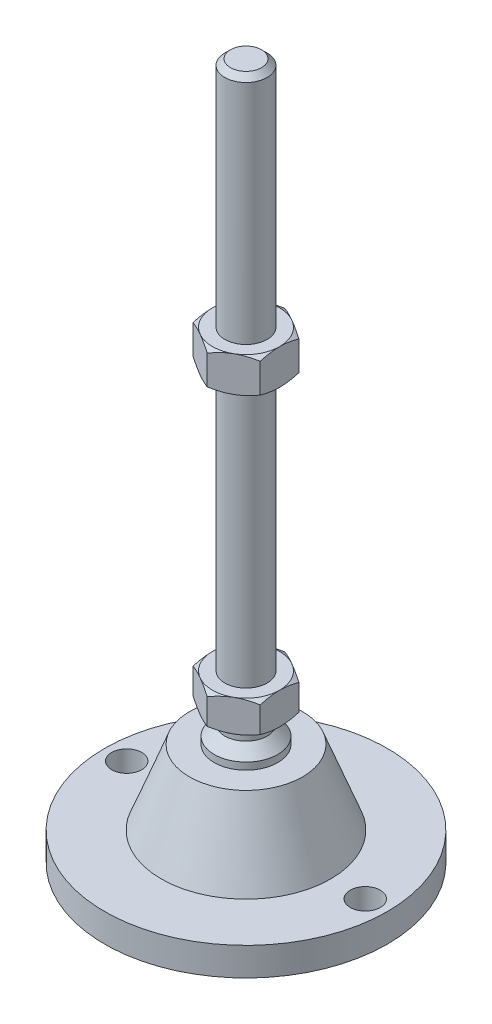
from build123d import *

# Parameters (mm, degrees)
EXTRUDE_1_DEPTH     = 9
EXTRUDE_2_DEPTH     = 10
SKETCH_5_R          = 4.25
CUT_EXTRUDE_1_DEPTH = 9


with BuildPart() as part:
    # Эскиз1 → Повернуть1 (revolve)
    with BuildSketch(Plane.XY, mode=Mode.PRIVATE) as revolve_1_sk:
        Polygon((0, 0), (-40, 0), (-40, 8), (-24, 8), (-16, 29), (-9, 29), (-9, 31), (-6, 34), (-6, 38), (-6, 47), (-6, 195.4), (-4.4, 197), (0, 197), align=None)
    revolve(revolve_1_sk.sketch.rotate(Axis((0, 0, 0), (0, 1, 0)), 180), axis=Axis((0, 0, 0), (0, 1, 0)))  # turned: the seam where the file's is

    # Эскиз2 → Бобышка-Вытянуть1 (add)
    with BuildSketch(Plane(origin=(0, 38, 0), x_dir=(1, 0, 0), z_dir=(0, 1, 0))):
        Polygon((0, 10.969655115), (-9.5, 5.484827557), (-9.5, -5.484827557), (0, -10.969655115), (9.5, -5.484827557), (9.5, 5.484827557), align=None)
    extrude(amount=EXTRUDE_1_DEPTH)

    # Эскиз3 → Бобышка-Вытянуть2 (add)
    with BuildSketch(Plane(origin=(0, 121.2, 0), x_dir=(1, 0, 0), z_dir=(0, 1, 0))):
        Polygon((9.5, 5.484827557), (0, 10.969655115), (-9.5, 5.484827557), (-9.5, -5.484827557), (0, -10.969655115), (9.5, -5.484827557), align=None)
    extrude(amount=EXTRUDE_2_DEPTH)

    # Эскиз4 → Вырез-Повернуть2 (revolve, cut)
    with BuildSketch(Plane.XY, mode=Mode.PRIVATE) as cut_revolve_2_sk:
        Polygon((-18.160254038, 131.2), (-9.5, 131.2), (-18.160254038, 126.2), align=None)
        Polygon((-18.160254038, 121.2), (-18.160254038, 126.2), (-9.5, 121.2), align=None)
        Polygon((-17.294228634, 47), (-17.294228634, 42.5), (-9.5, 47), align=None)
        Polygon((-17.294228634, 42.5), (-17.294228634, 38), (-9.5, 38), align=None)
    revolve(cut_revolve_2_sk.sketch.rotate(Axis((0, 197, 0), (0, -1, 0)), 180), axis=Axis((0, 197, 0), (0, -1, 0)), mode=Mode.SUBTRACT)  # turned: the seam where the file's is

    # Эскиз5 → Вырез-Вытянуть1 (cut, through all)
    with BuildSketch(Plane(origin=(0, 8, 0), x_dir=(1, 0, 0), z_dir=(0, 1, 0))):
        with Locations(Location((-33.75, 0, 0), (0, 0, 180))):  # turned: the seam where the file's is
            Circle(SKETCH_5_R)
        with Locations(Location((33.75, 0, 0), (0, 0, 180))):  # turned: the seam where the file's is
            Circle(SKETCH_5_R)
    extrude(amount=-CUT_EXTRUDE_1_DEPTH, mode=Mode.SUBTRACT)


solid = part.part
